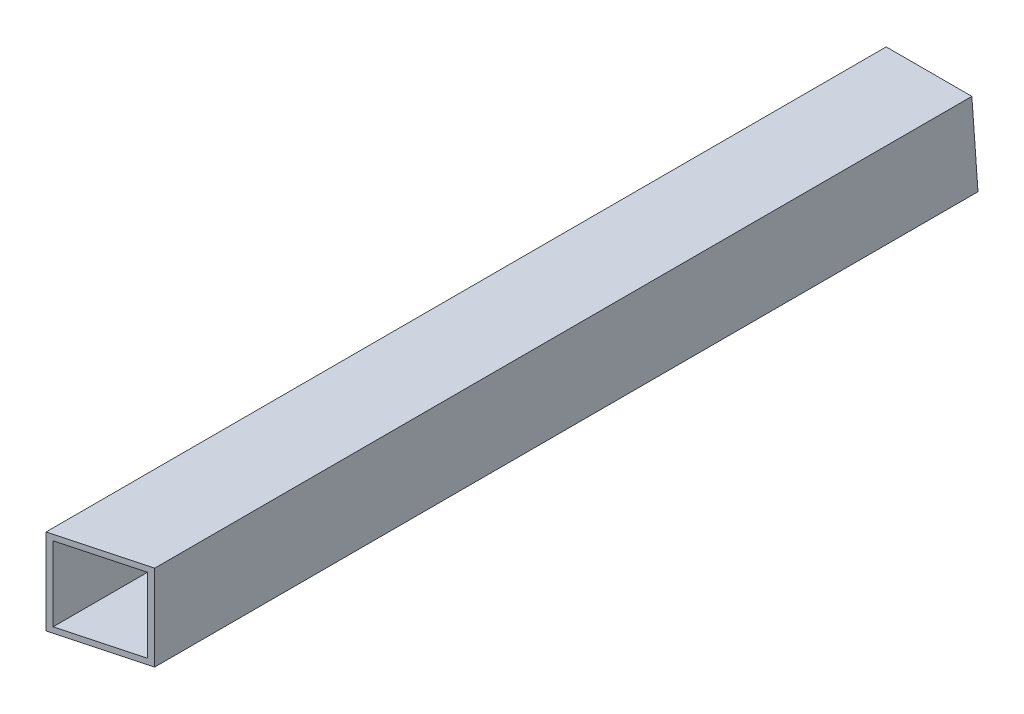
from build123d import *

# Parameters (mm, degrees)
SKETCH1_W           = 25.4
SKETCH1_H           = 25.4
SKETCH1_W_2         = 22.098
SKETCH1_H_2         = 22.098
BOSS_EXTRUDE1_DEPTH = 250
SKETCH5_W           = 25.4
SKETCH5_H           = 25.4
SKETCH5_W_2         = 22.098
SKETCH5_H_2         = 22.098
BOSS_EXTRUDE2_DEPTH = 25.4
CUT_EXTRUDE1_DEPTH  = 165.021579309
CUT_EXTRUDE2_DEPTH  = 26.4


with BuildPart() as part:
    # Sketch1 → Boss-Extrude1 (new body)
    with BuildSketch(Plane.XY):
        Rectangle(SKETCH1_W, SKETCH1_H)
        Rectangle(SKETCH1_W_2, SKETCH1_H_2, mode=Mode.SUBTRACT)
    extrude(amount=-BOSS_EXTRUDE1_DEPTH)

    # Sketch5 → Boss-Extrude2 (add)
    with BuildSketch(Plane(origin=(0, 0, -250), x_dir=(-1, 0, 0), z_dir=(0, 0, -1))):
        Rectangle(SKETCH5_W, SKETCH5_H)
        Rectangle(SKETCH5_W_2, SKETCH5_H_2, mode=Mode.SUBTRACT)
    extrude(amount=BOSS_EXTRUDE2_DEPTH)

    # Sketch6 → Cut-Extrude1 (cut, through all)
    with BuildSketch(Plane(origin=(-151.321579309, -359.319373916, -111.97168159), x_dir=(0, 0, 1), z_dir=(1, 0, 0))):
        Polygon((-136.210945072, -384.704102096), (-139.845691747, -333.934645736), (-224.95481734, -363.340122949), align=None)
    extrude(amount=CUT_EXTRUDE1_DEPTH, mode=Mode.SUBTRACT)

    # Sketch7 → Cut-Extrude2 (cut, through all)
    with BuildSketch(Plane.XZ.offset(12.7)):
        Polygon((-12.7, 0), (24.645207819, -10.006618276), (24.645207819, 0), align=None)
    extrude(amount=-CUT_EXTRUDE2_DEPTH, mode=Mode.SUBTRACT)


solid = part.part
